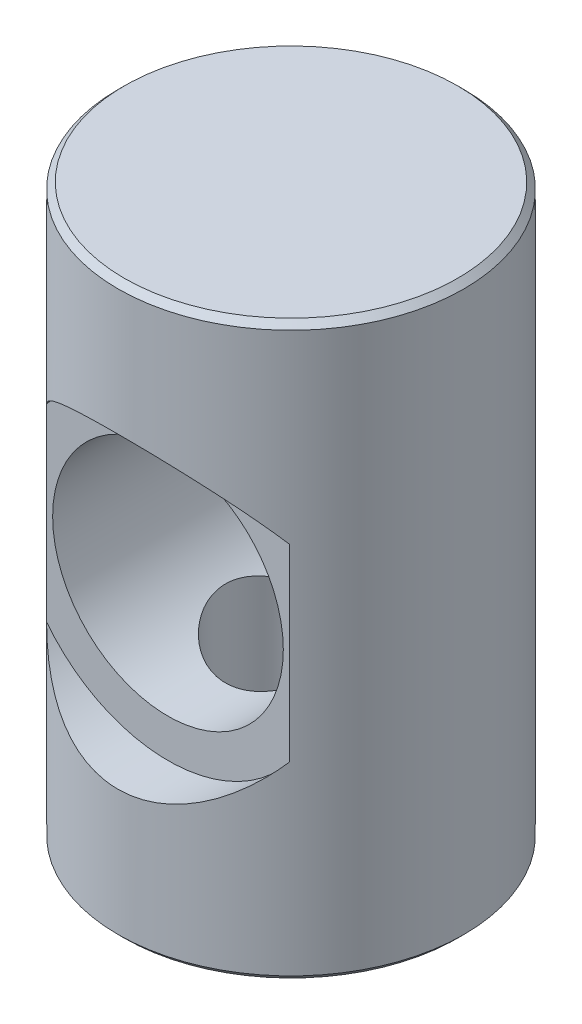
from build123d import *

# Parameters (mm, degrees)
SKETCH1_R                    = 7.1374
BOSS_EXTRUDE1_DEPTH          = 23.5966
CHAMFER1_SIZE                = 0.254
CHAMFER2_SIZE                = 0.254
SKETCH2_R                    = 4.7625
CUT_EXTRUDE1_DEPTH           = 7.1755
SKETCH3_R                    = 6.35
CUT_EXTRUDE2_DEPTH           = 28.513757958
F_1_4_28_TAPPED_HOLE1_REACH  = 27.665
F_1_4_28_TAPPED_HOLE1_BORE_R = 2.7051


with BuildPart() as part:
    # Sketch1 → Boss-Extrude1 (new body)
    with BuildSketch(Plane(origin=(0, 0, 0), x_dir=(1, 0, 0), z_dir=(0, 1, 0))):
        with Locations(Location((0, 0, 0), (0, 0, 90))):
            Circle(SKETCH1_R)
    extrude(amount=BOSS_EXTRUDE1_DEPTH)

    # Chamfer1
    chamfer1_edges = [part.edges().sort_by_distance(p)[0] for p in [
        (0, 0, 7.1374),
    ]]
    chamfer(chamfer1_edges, length=CHAMFER1_SIZE)

    # Chamfer2
    chamfer2_edges = [part.edges().sort_by_distance(p)[0] for p in [
        (0, 23.5966, 7.1374),
    ]]
    chamfer(chamfer2_edges, length=CHAMFER2_SIZE)

    # Sketch2 → Cut-Extrude1 (cut, symmetric)
    with BuildSketch(Plane.XY):
        with Locations(Location((0, 11.7983, 0), (0, 0, 89.999999998))):
            Circle(SKETCH2_R)
    extrude(amount=CUT_EXTRUDE1_DEPTH, both=True, mode=Mode.SUBTRACT)

    # Sketch3 → Cut-Extrude2 (cut, through all)
    with BuildSketch(Plane.XY.offset(5.08)):
        with Locations((0, 11.7983)):
            Circle(SKETCH3_R)
    cut_extrude2 = extrude(amount=CUT_EXTRUDE2_DEPTH, mode=Mode.SUBTRACT)

    # Mirror1: Cut-Extrude2 across plane
    add(cut_extrude2.mirror(Plane.XY), mode=Mode.SUBTRACT)

    # 1/4-28 Tapped Hole1 bore → 1/4-28 Tapped Hole1 (cut, up to next)
    with BuildSketch(Plane(origin=(0, 0, 0), x_dir=(-1, 0, 0), z_dir=(0, -1, 0)), mode=Mode.PRIVATE) as f_1_4_28_tapped_hole1_sk1:
        Circle(F_1_4_28_TAPPED_HOLE1_BORE_R)
    f_1_4_28_tapped_hole1_tool1 = extrude(f_1_4_28_tapped_hole1_sk1.sketch, amount=-F_1_4_28_TAPPED_HOLE1_REACH, mode=Mode.PRIVATE) & part.part
    add(f_1_4_28_tapped_hole1_tool1.solids().sort_by_distance((0, 0, 0))[0], mode=Mode.SUBTRACT)


solid = part.part
